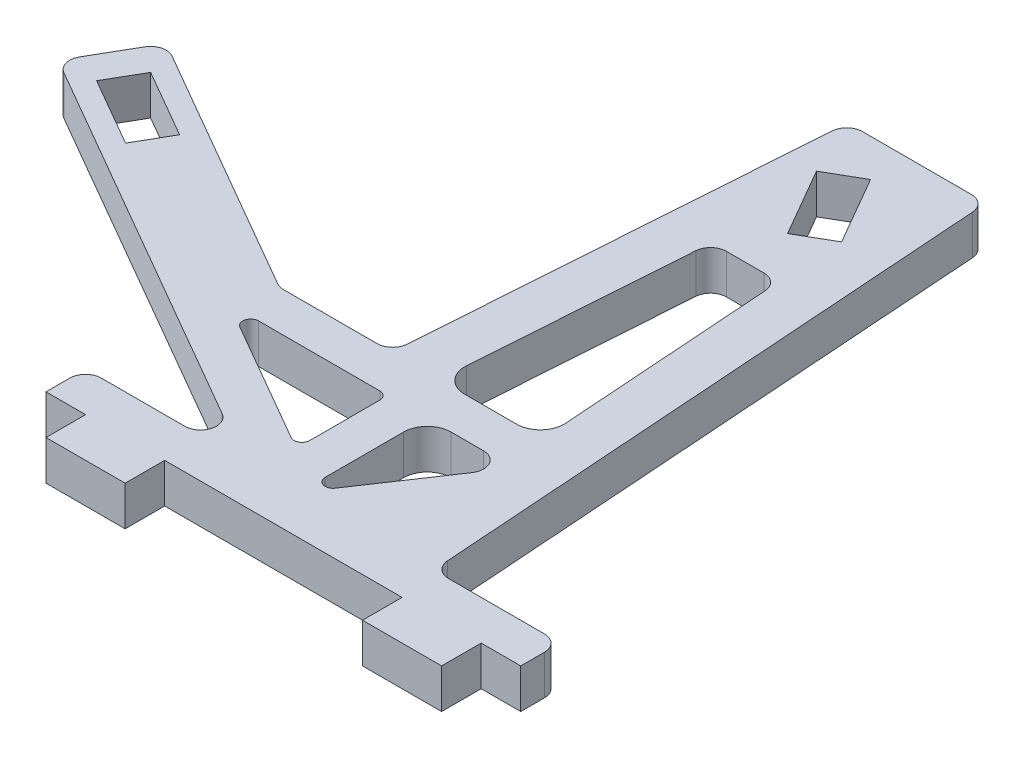
from build123d import *

# Parameters (mm, degrees)
EXTRUDE_1_DEPTH     = 5
CUT_EXTRUDE_1_DEPTH = 6
FILLET_1_R          = 2
FILLET_2_R          = 2
FILLET_3_R          = 3
FILLET_4_R          = 3
FILLET_5_R          = 3
FILLET_6_R          = 2
FILLET_7_R          = 1
FILLET_8_R          = 1
FILLET_9_R          = 1
FILLET_10_R         = 1
FILLET_11_R         = 2
FILLET_12_R         = 2
FILLET_13_R         = 2
FILLET_14_R         = 2
FILLET_15_R         = 2
FILLET_16_R         = 2


with BuildPart() as part:
    # 草图1 → 凸台-拉伸1 (new body)
    with BuildSketch(Plane(origin=(0, 0, 0), x_dir=(1, 0, 0), z_dir=(0, 1, 0))):
        Polygon((-5, 5), (0, 5), (0, 0), (10, 0), (10, 5), (40, 5), (40, 0), (50, 0), (50, 5), (55, 5), (55, 10), (39, 10), (33.75, 85.078497848), (16.25, 85.078497848), (12.482276941, 31.197547838), (-1.715229851, 31.197547838), (-35.526844906, 50.718692892), (-40.526844906, 42.058438854), (15, 10), (-5, 10), align=None)
    extrude(amount=EXTRUDE_1_DEPTH)

    # 草图2 → 切除-拉伸1 (cut, through all)
    with BuildSketch(Plane(origin=(0, 5, 0), x_dir=(1, 0, 0), z_dir=(0, 1, 0))):
        Polygon((-35.854277493, 42.247482146), (-27.194023456, 37.247482146), (-24.694023456, 41.577609165), (-33.354277493, 46.577609165), align=None)
        Polygon((28.868403571, 71.682200114), (23.868403571, 80.342454152), (19.538276552, 77.842454152), (24.538276552, 69.182200114), align=None)
        Polygon((-3.054975814, 26.197547838), (17, 26.197547838), (17, 14.618802154), align=None)
        Polygon((20.75, 63.374046916), (29.25, 63.374046916), (31.5, 31.197547838), (18.5, 31.197547838), align=None)
        Polygon((22, 26.197547838), (22, 10), (32.855147628, 26.197547838), align=None)
    extrude(amount=-CUT_EXTRUDE_1_DEPTH, mode=Mode.SUBTRACT)

    # 圆角1
    fillet_1_edges = [part.edges().sort_by_distance(p)[0] for p in [
        (20.75, 2.5, -63.374046916),
    ]]
    fillet(fillet_1_edges, radius=FILLET_1_R)

    # 圆角2
    fillet_2_edges = [part.edges().sort_by_distance(p)[0] for p in [
        (29.25, 2.5, -63.374046916),
    ]]
    fillet(fillet_2_edges, radius=FILLET_2_R)

    # 圆角3
    fillet_3_edges = [part.edges().sort_by_distance(p)[0] for p in [
        (18.5, 2.5, -31.197547838),
    ]]
    fillet(fillet_3_edges, radius=FILLET_3_R)

    # 圆角4
    fillet_4_edges = [part.edges().sort_by_distance(p)[0] for p in [
        (31.5, 2.5, -31.197547838),
    ]]
    fillet(fillet_4_edges, radius=FILLET_4_R)

    # 圆角5
    fillet_5_edges = [part.edges().sort_by_distance(p)[0] for p in [
        (22, 2.5, -26.197547838),
    ]]
    fillet(fillet_5_edges, radius=FILLET_5_R)

    # 圆角6
    fillet_6_edges = [part.edges().sort_by_distance(p)[0] for p in [
        (32.855147628, 2.5, -26.197547838),
    ]]
    fillet(fillet_6_edges, radius=FILLET_6_R)

    # 圆角7
    fillet_7_edges = [part.edges().sort_by_distance(p)[0] for p in [
        (22, 2.5, -10),
    ]]
    fillet(fillet_7_edges, radius=FILLET_7_R)

    # 圆角8
    fillet_8_edges = [part.edges().sort_by_distance(p)[0] for p in [
        (17, 2.5, -14.618802154),
    ]]
    fillet(fillet_8_edges, radius=FILLET_8_R)

    # 圆角9
    fillet_9_edges = [part.edges().sort_by_distance(p)[0] for p in [
        (-3.054975814, 2.5, -26.197547838),
    ]]
    fillet(fillet_9_edges, radius=FILLET_9_R)

    # 圆角10
    fillet_10_edges = [part.edges().sort_by_distance(p)[0] for p in [
        (17, 2.5, -26.197547838),
    ]]
    fillet(fillet_10_edges, radius=FILLET_10_R)

    # 圆角11
    fillet_11_edges = [part.edges().sort_by_distance(p)[0] for p in [
        (-5, 2.5, -10),
    ]]
    fillet(fillet_11_edges, radius=FILLET_11_R)

    # 圆角12
    fillet_12_edges = [part.edges().sort_by_distance(p)[0] for p in [
        (55, 2.5, -10),
    ]]
    fillet(fillet_12_edges, radius=FILLET_12_R)

    # 圆角13
    fillet_13_edges = [part.edges().sort_by_distance(p)[0] for p in [
        (39, 2.5, -10),
    ]]
    fillet(fillet_13_edges, radius=FILLET_13_R)

    # 圆角14
    fillet_14_edges = [part.edges().sort_by_distance(p)[0] for p in [
        (15, 2.5, -10),
    ]]
    fillet(fillet_14_edges, radius=FILLET_14_R)

    # 圆角15
    fillet_15_edges = [part.edges().sort_by_distance(p)[0] for p in [
        (-40.526844906, 2.5, -42.058438854),
        (-35.526844906, 2.5, -50.718692892),
    ]]
    fillet(fillet_15_edges, radius=FILLET_15_R)

    # 圆角16
    fillet_16_edges = [part.edges().sort_by_distance(p)[0] for p in [
        (33.75, 2.5, -85.078497848),
        (-1.715229851, 2.5, -31.197547838),
        (12.482276941, 2.5, -31.197547838),
        (16.25, 2.5, -85.078497848),
    ]]
    fillet(fillet_16_edges, radius=FILLET_16_R)


solid = part.part
